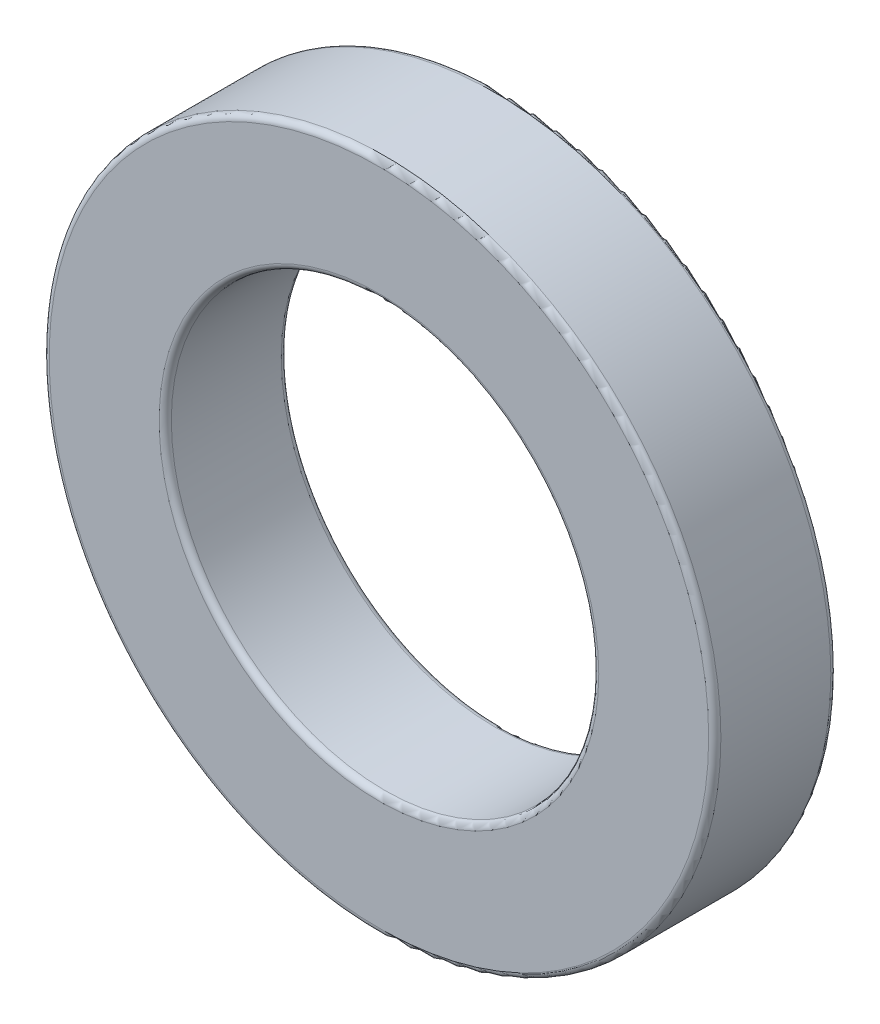
from build123d import *

# Parameters (mm, degrees)
ESQUISSE1_R             = 55
ESQUISSE1_R_2           = 35
BOSS_EXTRU_1_DEPTH      = 20
CONG_6_R                = 1
ESQUISSE3_R             = 49.95
ESQUISSE3_R_2           = 41.45
ENL_V_MAT_EXTRU_1_DEPTH = 4


with BuildPart() as part:
    # Esquisse1 → Boss.-Extru.1 (new body)
    with BuildSketch(Plane.XY):
        Circle(ESQUISSE1_R)
        Circle(ESQUISSE1_R_2, mode=Mode.SUBTRACT)
    extrude(amount=BOSS_EXTRU_1_DEPTH)

    # Congé6
    cong_6_edges = [part.edges().sort_by_distance(p)[0] for p in [
        (-55, 0, 0),
        (-55, 0, 20),
        (-35, 0, 0),
        (-35, 0, 20),
    ]]
    fillet(cong_6_edges, radius=CONG_6_R)

    # Esquisse3 → Enlèv. mat.-Extru.1 (cut)
    with BuildSketch(Plane(origin=(0, 0, 0), x_dir=(-1, 0, 0), z_dir=(0, 0, -1))):
        Circle(ESQUISSE3_R)
        Circle(ESQUISSE3_R_2, mode=Mode.SUBTRACT)
    extrude(amount=-ENL_V_MAT_EXTRU_1_DEPTH, mode=Mode.SUBTRACT)


solid = part.part
